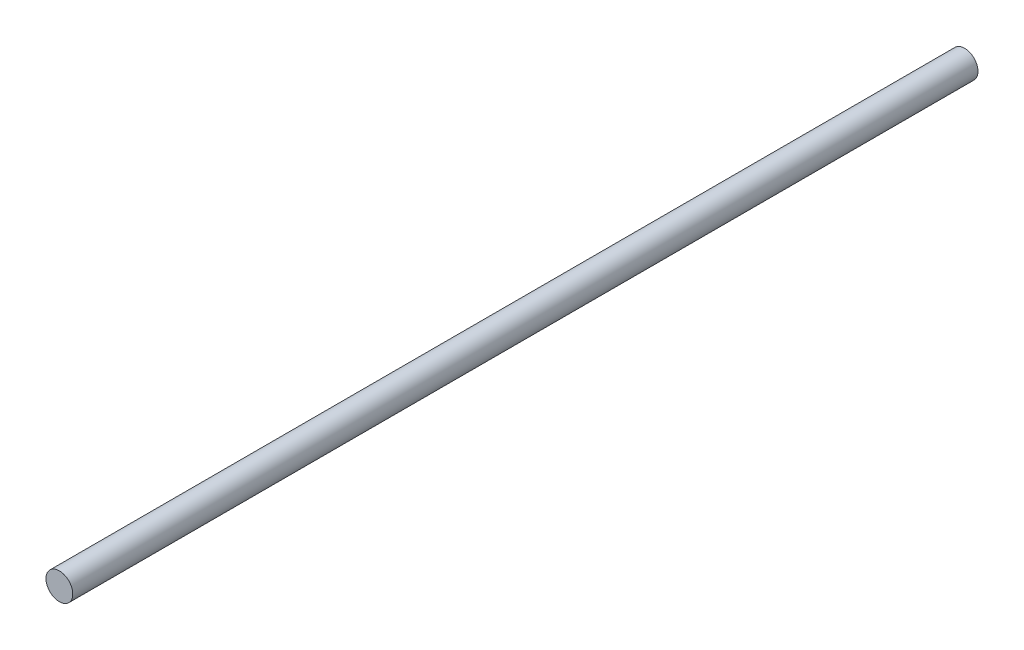
from build123d import *

# Parameters (mm, degrees)
SKETCH1_R           = 10
BOSS_EXTRUDE1_DEPTH = 338


with BuildPart() as part:
    # Sketch1 → Boss-Extrude1 (new body, symmetric)
    with BuildSketch(Plane.XY):
        Circle(SKETCH1_R)
    extrude(amount=BOSS_EXTRUDE1_DEPTH, both=True)


solid = part.part
